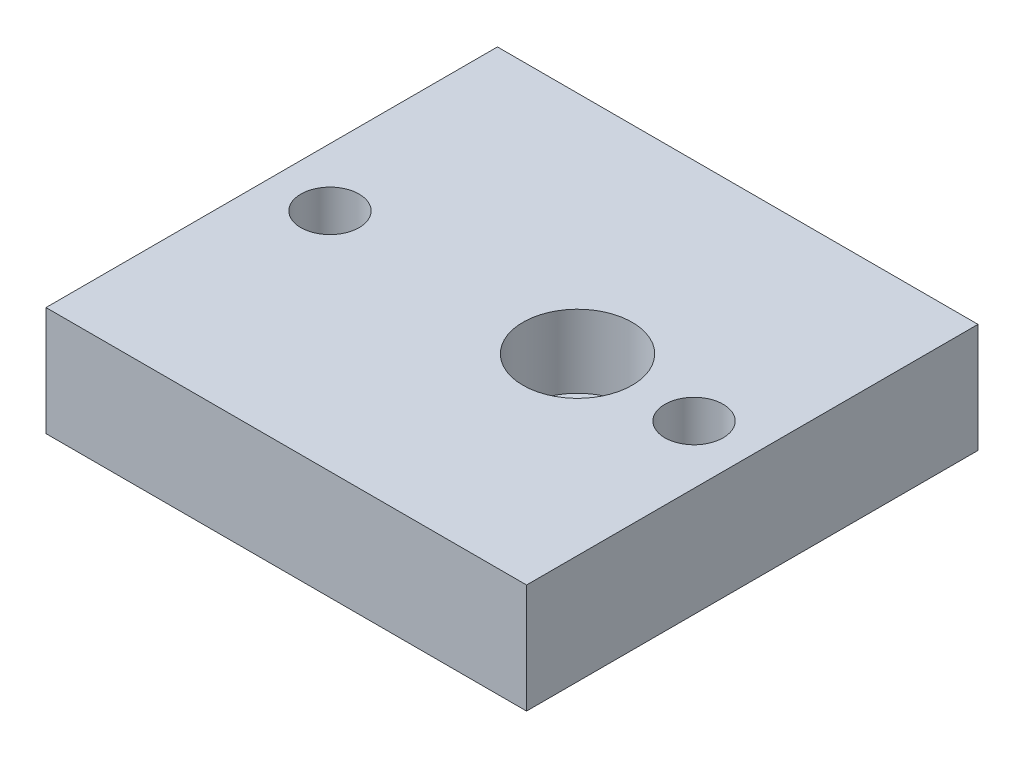
from build123d import *

# Parameters (mm, degrees)
CROQUIS1_W              = 66
CROQUIS1_H              = 62
SALIENTE_EXTRUIR1_DEPTH = 15
CROQUIS2_R              = 5
CROQUIS2_R_2            = 4
CORTAR_EXTRUIR1_DEPTH   = 15
CROQUIS3_R              = 7.5
CORTAR_EXTRUIR2_DEPTH   = 10


with BuildPart() as part:
    # Croquis1 → Saliente-Extruir1 (new body)
    with BuildSketch(Plane(origin=(0, 0, 0), x_dir=(1, 0, 0), z_dir=(0, 1, 0))):
        Rectangle(CROQUIS1_W, CROQUIS1_H)
    extrude(amount=SALIENTE_EXTRUIR1_DEPTH)

    # Croquis2 → Cortar-Extruir1 (cut)
    with BuildSketch(Plane(origin=(0, 15, 0), x_dir=(1, 0, 0), z_dir=(0, 1, 0))):
        with Locations((9, 0)):
            Circle(CROQUIS2_R)
        with Locations((-25, 0)):
            Circle(CROQUIS2_R_2)
        with Locations((25, 0)):
            Circle(CROQUIS2_R_2)
    extrude(amount=-CORTAR_EXTRUIR1_DEPTH, mode=Mode.SUBTRACT)

    # Croquis3 → Cortar-Extruir2 (cut)
    with BuildSketch(Plane(origin=(0, 15, 0), x_dir=(1, 0, 0), z_dir=(0, 1, 0))):
        with Locations((9, 0)):
            Circle(CROQUIS3_R)
    extrude(amount=-CORTAR_EXTRUIR2_DEPTH, mode=Mode.SUBTRACT)


solid = part.part
